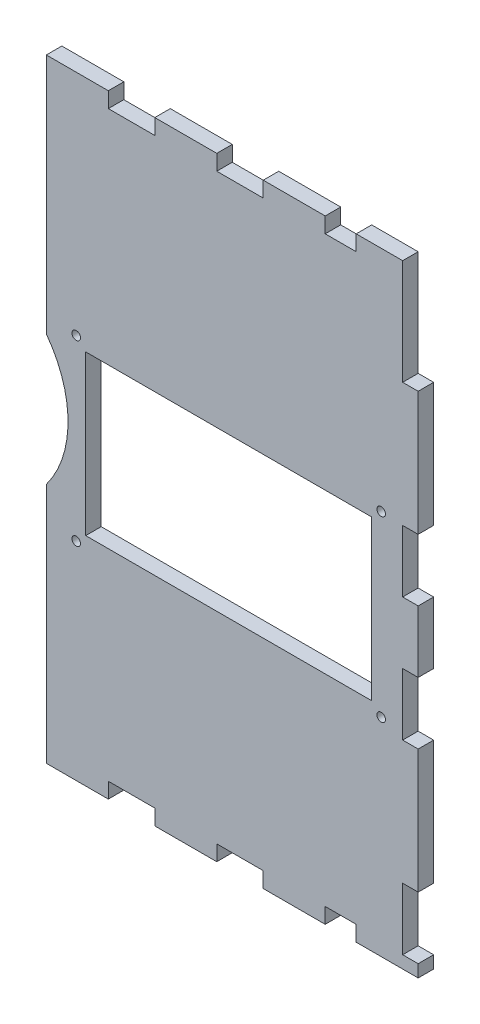
from build123d import *

# Parameters (mm, degrees)
SKETCH1_W               = 152.4
SKETCH1_H               = 251.46
BOSS_EXTRUDE1_DEPTH     = 6.35
SKETCH2_W               = 19.05
SKETCH2_H               = 6.35
SKETCH2_W_2             = 12.7
CUT_EXTRUDE1_DEPTH      = 6.35
SKETCH3_W               = 19.05
SKETCH3_H               = 6.35
SKETCH3_W_2             = 12.7
CUT_EXTRUDE2_DEPTH      = 1
CUT_EXTRUDE2_DEPTH_BACK = 6.35
SKETCH4_W               = 6.35
SKETCH4_H               = 25.4
SKETCH4_H_2             = 43.18
CUT_EXTRUDE3_DEPTH      = 6.35
SKETCH5_R               = 44.45
CUT_EXTRUDE4_DEPTH      = 7.35
SKETCH6_W               = 117.22
SKETCH6_H               = 65.22
SKETCH6_R               = 1.75
CUT_EXTRUDE5_DEPTH      = 7.35


with BuildPart() as part:
    # Sketch1 → Boss-Extrude1 (new body)
    with BuildSketch(Plane.XY):
        with Locations((-209.55, -120.65)):
            Rectangle(SKETCH1_W, SKETCH1_H)
    extrude(amount=BOSS_EXTRUDE1_DEPTH)

    # Sketch2 → Cut-Extrude1 (cut)
    with BuildSketch(Plane(origin=(0, 5.08, 0), x_dir=(1, 0, 0), z_dir=(0, 1, 0))):
        with Locations((-250.825, -3.175)):
            Rectangle(SKETCH2_W, SKETCH2_H)
        with Locations((-206.375, -3.175)):
            Rectangle(SKETCH2_W, SKETCH2_H)
        with Locations((-165.1, -3.175)):
            Rectangle(SKETCH2_W_2, SKETCH2_H)
    extrude(amount=-CUT_EXTRUDE1_DEPTH, mode=Mode.SUBTRACT)

    # Sketch3 → Cut-Extrude2 (cut, two sides)
    with BuildSketch(Plane.XZ.offset(246.38)) as cut_extrude2_sk:
        with Locations((-250.825, 3.175)):
            Rectangle(SKETCH3_W, SKETCH3_H)
        with Locations((-206.375, 3.175)):
            Rectangle(SKETCH3_W, SKETCH3_H)
        with Locations((-165.1, 3.175)):
            Rectangle(SKETCH3_W_2, SKETCH3_H)
    extrude(amount=CUT_EXTRUDE2_DEPTH, mode=Mode.SUBTRACT)
    extrude(cut_extrude2_sk.sketch, amount=-CUT_EXTRUDE2_DEPTH_BACK, mode=Mode.SUBTRACT)

    # Sketch4 → Cut-Extrude3 (cut)
    with BuildSketch(Plane.XY.offset(6.35)):
        with Locations((-136.525, -152.4)):
            Rectangle(SKETCH4_W, SKETCH4_H)
        with Locations((-136.525, -101.6)):
            Rectangle(SKETCH4_W, SKETCH4_H)
        with Locations((-136.525, -16.51)):
            Rectangle(SKETCH4_W, SKETCH4_H_2)
        with Locations((-136.525, -228.6)):
            Rectangle(SKETCH4_W, SKETCH4_H)
    extrude(amount=-CUT_EXTRUDE3_DEPTH, mode=Mode.SUBTRACT)

    # Sketch5 → Cut-Extrude4 (cut, through all)
    with BuildSketch(Plane.XY.offset(6.35)):
        with Locations((-321.31, -120.65)):
            Circle(SKETCH5_R)
    extrude(amount=-CUT_EXTRUDE4_DEPTH, mode=Mode.SUBTRACT)

    # Sketch6 → Cut-Extrude5 (cut, through all)
    with BuildSketch(Plane.XY.offset(6.35)):
        with Locations((-211.01, -124.87)):
            Rectangle(SKETCH6_W, SKETCH6_H)
        with Locations((-273.51, -88.37)):
            Circle(SKETCH6_R)
        with Locations((-273.51, -161.37)):
            Circle(SKETCH6_R)
        with Locations((-148.51, -88.37)):
            Circle(SKETCH6_R)
        with Locations((-148.51, -161.37)):
            Circle(SKETCH6_R)
    extrude(amount=-CUT_EXTRUDE5_DEPTH, mode=Mode.SUBTRACT)


solid = part.part
